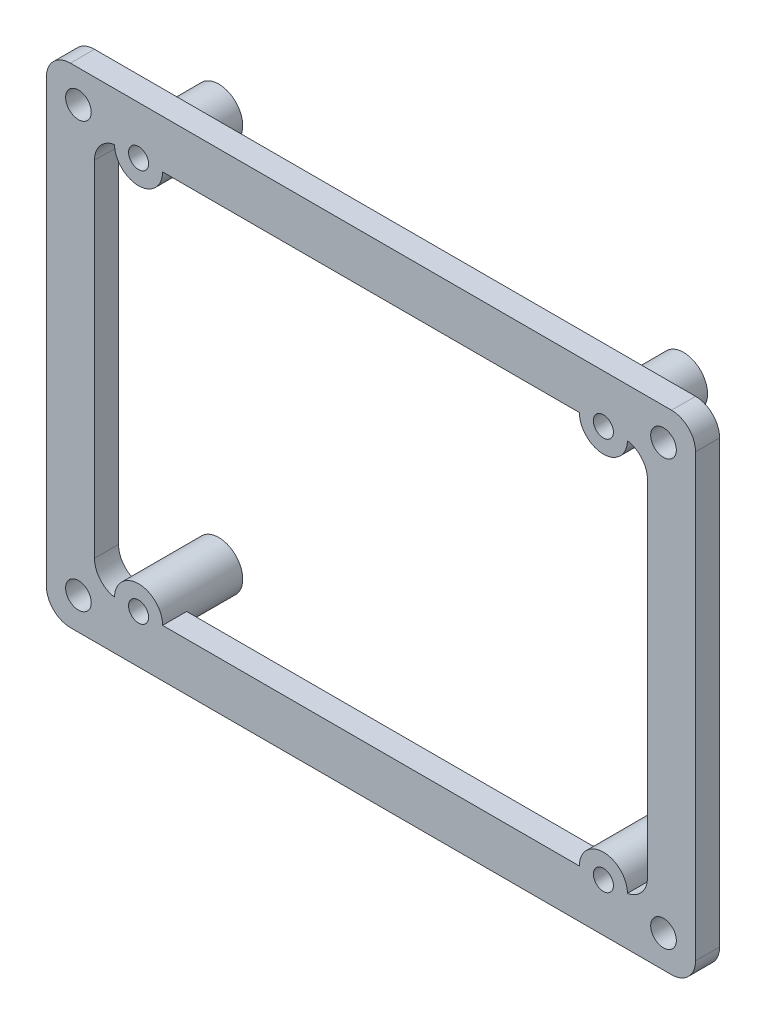
from build123d import *

# Parameters (mm, degrees)
SKETCH1_W           = 81
SKETCH1_H           = 61
SKETCH1_W_2         = 69
SKETCH1_H_2         = 49
EXTRUDE_THIN1_DEPTH = 3
SKETCH2_R           = 1.6
CUT_EXTRUDE1_DEPTH  = 3
FILLET1_R           = 3
SKETCH4_R           = 3
BOSS_EXTRUDE1_DEPTH = 10
CUT_EXTRUDE2_REACH  = 12
SKETCH5_R           = 1.25


with BuildPart() as part:
    # Sketch1 → Extrude-Thin1 (new body)
    with BuildSketch(Plane.XY):
        Rectangle(SKETCH1_W, SKETCH1_H)
        Rectangle(SKETCH1_W_2, SKETCH1_H_2, mode=Mode.SUBTRACT)
    extrude(amount=EXTRUDE_THIN1_DEPTH)

    # Sketch2 → Cut-Extrude1 (cut)
    with BuildSketch(Plane.XY.offset(3)):
        with Locations((-36.5, 26.5)):
            Circle(SKETCH2_R)
        with Locations((36.5, 26.5)):
            Circle(SKETCH2_R)
        with Locations((36.5, -26.5)):
            Circle(SKETCH2_R)
        with Locations((-36.5, -26.5)):
            Circle(SKETCH2_R)
    extrude(amount=-CUT_EXTRUDE1_DEPTH, mode=Mode.SUBTRACT)

    # Fillet1
    fillet1_edges = [part.edges().sort_by_distance(p)[0] for p in [
        (-34.5, 24.5, 1.5),
        (-34.5, -24.5, 1.5),
        (34.5, -24.5, 1.5),
        (34.5, 24.5, 1.5),
        (-40.5, 30.5, 1.5),
        (40.5, 30.5, 1.5),
        (40.5, -30.5, 1.5),
        (-40.5, -30.5, 1.5),
    ]]
    fillet(fillet1_edges, radius=FILLET1_R)

    # Sketch4 → Boss-Extrude1 (add)
    with BuildSketch(Plane.XY.offset(3)):
        with Locations((-29, 24.5)):
            Circle(SKETCH4_R)
        with Locations((29, 24.5)):
            Circle(SKETCH4_R)
        with Locations((29, -24.5)):
            Circle(SKETCH4_R)
        with Locations((-29, -24.5)):
            Circle(SKETCH4_R)
    extrude(amount=-BOSS_EXTRUDE1_DEPTH)

    # Sketch5 → Cut-Extrude2 (cut, up to next)
    with BuildSketch(Plane(origin=(0, 0, -7), x_dir=(-1, 0, 0), z_dir=(0, 0, -1)), mode=Mode.PRIVATE) as cut_extrude2_sk1:
        with Locations((-29, 24.5)):
            Circle(SKETCH5_R)
    cut_extrude2_tool1 = extrude(cut_extrude2_sk1.sketch, amount=-CUT_EXTRUDE2_REACH, mode=Mode.PRIVATE) & part.part
    add(cut_extrude2_tool1.solids().sort_by_distance((29, 24.5, -7))[0], mode=Mode.SUBTRACT)
    # Sketch5 → Cut-Extrude2 (cut, up to next)
    with BuildSketch(Plane(origin=(0, 0, -7), x_dir=(-1, 0, 0), z_dir=(0, 0, -1)), mode=Mode.PRIVATE) as cut_extrude2_sk2:
        with Locations((29, 24.5)):
            Circle(SKETCH5_R)
    cut_extrude2_tool2 = extrude(cut_extrude2_sk2.sketch, amount=-CUT_EXTRUDE2_REACH, mode=Mode.PRIVATE) & part.part
    add(cut_extrude2_tool2.solids().sort_by_distance((-29, 24.5, -7))[0], mode=Mode.SUBTRACT)
    # Sketch5 → Cut-Extrude2 (cut, up to next)
    with BuildSketch(Plane(origin=(0, 0, -7), x_dir=(-1, 0, 0), z_dir=(0, 0, -1)), mode=Mode.PRIVATE) as cut_extrude2_sk3:
        with Locations((-29, -24.5)):
            Circle(SKETCH5_R)
    cut_extrude2_tool3 = extrude(cut_extrude2_sk3.sketch, amount=-CUT_EXTRUDE2_REACH, mode=Mode.PRIVATE) & part.part
    add(cut_extrude2_tool3.solids().sort_by_distance((29, -24.5, -7))[0], mode=Mode.SUBTRACT)
    # Sketch5 → Cut-Extrude2 (cut, up to next)
    with BuildSketch(Plane(origin=(0, 0, -7), x_dir=(-1, 0, 0), z_dir=(0, 0, -1)), mode=Mode.PRIVATE) as cut_extrude2_sk4:
        with Locations((29, -24.5)):
            Circle(SKETCH5_R)
    cut_extrude2_tool4 = extrude(cut_extrude2_sk4.sketch, amount=-CUT_EXTRUDE2_REACH, mode=Mode.PRIVATE) & part.part
    add(cut_extrude2_tool4.solids().sort_by_distance((-29, -24.5, -7))[0], mode=Mode.SUBTRACT)


solid = part.part
